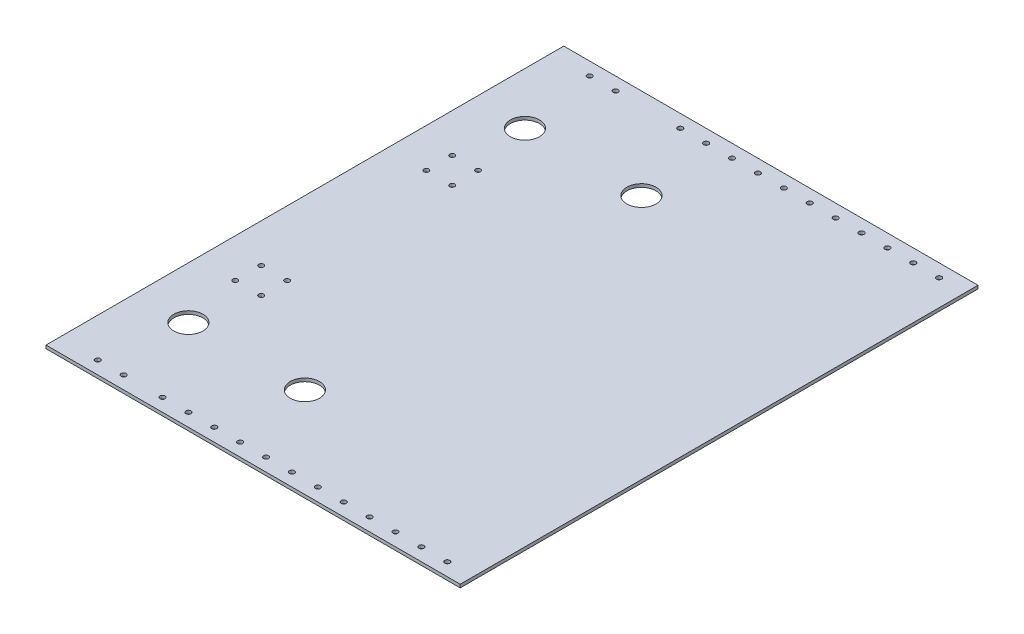
from build123d import *

# Parameters (mm, degrees)
SKETCH1_W               = 406.4
SKETCH1_H               = 508
BOSS_EXTRUDE1_DEPTH     = 3.175
SKETCH2_R               = 14.2875
CUT_EXTRUDE1_DEPTH      = 3.175
SKETCH3_R               = 2.4892
CUT_EXTRUDE2_DEPTH      = 1
CUT_EXTRUDE2_DEPTH_BACK = 4.175
SKETCH4_R               = 2.413
CUT_EXTRUDE3_DEPTH      = 1
CUT_EXTRUDE3_DEPTH_BACK = 4.175


with BuildPart() as part:
    # Sketch1 → Boss-Extrude1 (new body)
    with BuildSketch(Plane(origin=(0, 0, 0), x_dir=(1, 0, 0), z_dir=(0, 1, 0))):
        with Locations((203.2, 254)):
            Rectangle(SKETCH1_W, SKETCH1_H)
    extrude(amount=BOSS_EXTRUDE1_DEPTH)

    # Sketch2 → Cut-Extrude1 (cut)
    with BuildSketch(Plane(origin=(0, 3.175, 0), x_dir=(1, 0, 0), z_dir=(0, 1, 0))):
        with Locations((50.8, 419.1)):
            Circle(SKETCH2_R)
        with Locations((165.1, 419.1)):
            Circle(SKETCH2_R)
        with Locations((50.8, 88.9)):
            Circle(SKETCH2_R)
        with Locations((165.1, 88.9)):
            Circle(SKETCH2_R)
    extrude(amount=-CUT_EXTRUDE1_DEPTH, mode=Mode.SUBTRACT)

    # Sketch3 → Cut-Extrude2 (cut, two sides)
    with BuildSketch(Plane(origin=(0, 3.175, 0), x_dir=(1, 0, 0), z_dir=(0, 1, 0))) as cut_extrude2_sk:
        with Locations((38.1, 12.7)):
            Circle(SKETCH3_R)
        with Locations((63.5, 12.7)):
            Circle(SKETCH3_R)
        with Locations((127, 12.7)):
            Circle(SKETCH3_R)
        with Locations((152.4, 12.7)):
            Circle(SKETCH3_R)
        with Locations((177.8, 12.7)):
            Circle(SKETCH3_R)
        with Locations((203.2, 12.7)):
            Circle(SKETCH3_R)
        with Locations((228.6, 12.7)):
            Circle(SKETCH3_R)
        with Locations((254, 12.7)):
            Circle(SKETCH3_R)
        with Locations((279.4, 12.7)):
            Circle(SKETCH3_R)
        with Locations((304.8, 12.7)):
            Circle(SKETCH3_R)
        with Locations((330.2, 12.7)):
            Circle(SKETCH3_R)
        with Locations((355.6, 12.7)):
            Circle(SKETCH3_R)
        with Locations((381, 12.7)):
            Circle(SKETCH3_R)
        with Locations((381, 495.3)):
            Circle(SKETCH3_R)
        with Locations((355.6, 495.3)):
            Circle(SKETCH3_R)
        with Locations((330.2, 495.3)):
            Circle(SKETCH3_R)
        with Locations((304.8, 495.3)):
            Circle(SKETCH3_R)
        with Locations((279.4, 495.3)):
            Circle(SKETCH3_R)
        with Locations((254, 495.3)):
            Circle(SKETCH3_R)
        with Locations((228.6, 495.3)):
            Circle(SKETCH3_R)
        with Locations((203.2, 495.3)):
            Circle(SKETCH3_R)
        with Locations((177.8, 495.3)):
            Circle(SKETCH3_R)
        with Locations((152.4, 495.3)):
            Circle(SKETCH3_R)
        with Locations((127, 495.3)):
            Circle(SKETCH3_R)
        with Locations((63.5, 495.3)):
            Circle(SKETCH3_R)
        with Locations((38.1, 495.3)):
            Circle(SKETCH3_R)
        with Locations((101.6, 12.7)):
            Circle(SKETCH3_R)
    extrude(amount=CUT_EXTRUDE2_DEPTH, mode=Mode.SUBTRACT)
    extrude(cut_extrude2_sk.sketch, amount=-CUT_EXTRUDE2_DEPTH_BACK, mode=Mode.SUBTRACT)

    # Sketch4 → Cut-Extrude3 (cut, two sides)
    with BuildSketch(Plane.XZ) as cut_extrude3_sk:
        with Locations((38.179625472, -334.938702735)):
            Circle(SKETCH4_R)
        with Locations((63.579625472, -334.938702735)):
            Circle(SKETCH4_R)
        with Locations((63.579625472, -360.338702735)):
            Circle(SKETCH4_R)
        with Locations((38.179625472, -360.338702735)):
            Circle(SKETCH4_R)
        with Locations((63.461499211, -173.060090351)):
            Circle(SKETCH4_R)
        with Locations((38.061499211, -173.060090351)):
            Circle(SKETCH4_R)
        with Locations((38.061499211, -147.660090351)):
            Circle(SKETCH4_R)
        with Locations((63.461499211, -147.660090351)):
            Circle(SKETCH4_R)
    extrude(amount=CUT_EXTRUDE3_DEPTH, mode=Mode.SUBTRACT)
    extrude(cut_extrude3_sk.sketch, amount=-CUT_EXTRUDE3_DEPTH_BACK, mode=Mode.SUBTRACT)


solid = part.part
